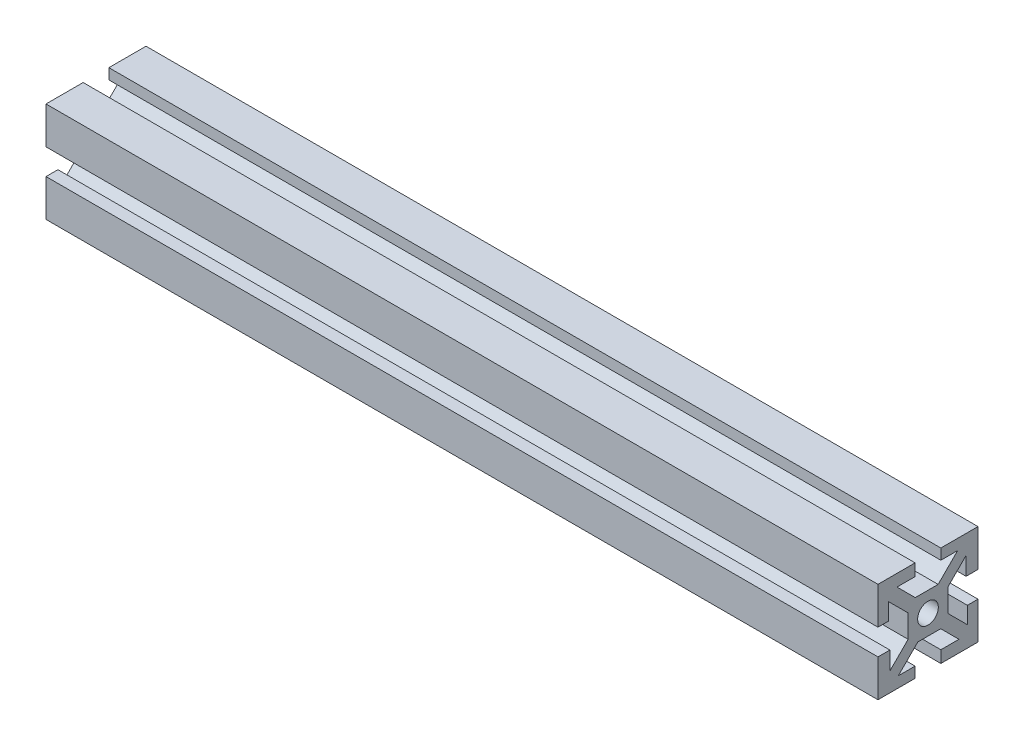
from build123d import *

# Parameters (mm, degrees)
SKETCH1_R           = 2.605
BOSS_EXTRUDE1_DEPTH = 209.55
CIRPATTERN1_COUNT   = 4


with BuildPart() as part:
    # Sketch1 → Boss-Extrude1 (new body)
    with BuildSketch(Plane(origin=(0, 0, 0), x_dir=(0, 0, -1), z_dir=(1, 0, 0))):
        Polygon((5, -5), (5, 3.203948776), (9.596194078, 7.800142853), (9.596194078, 3.24), (12.596194078, 3.24), (12.596194078, 12.596194078), (3.24, 12.596194078), (3.24, 9.921463197), (7.474873734, 9.921463197), (2.553410537, 5), (-5, 5), (-5, -5), align=None)
        Circle(SKETCH1_R, mode=Mode.SUBTRACT)
    boss_extrude1 = extrude(amount=BOSS_EXTRUDE1_DEPTH)

    # CirPattern1: Boss-Extrude1 ×4 about axis
    cirpattern1_axis = Axis((0, 0, 0), (1, 0, 0))
    for i in range(1, CIRPATTERN1_COUNT):
        add(boss_extrude1.rotate(cirpattern1_axis, i * 360 / CIRPATTERN1_COUNT))


solid = part.part
